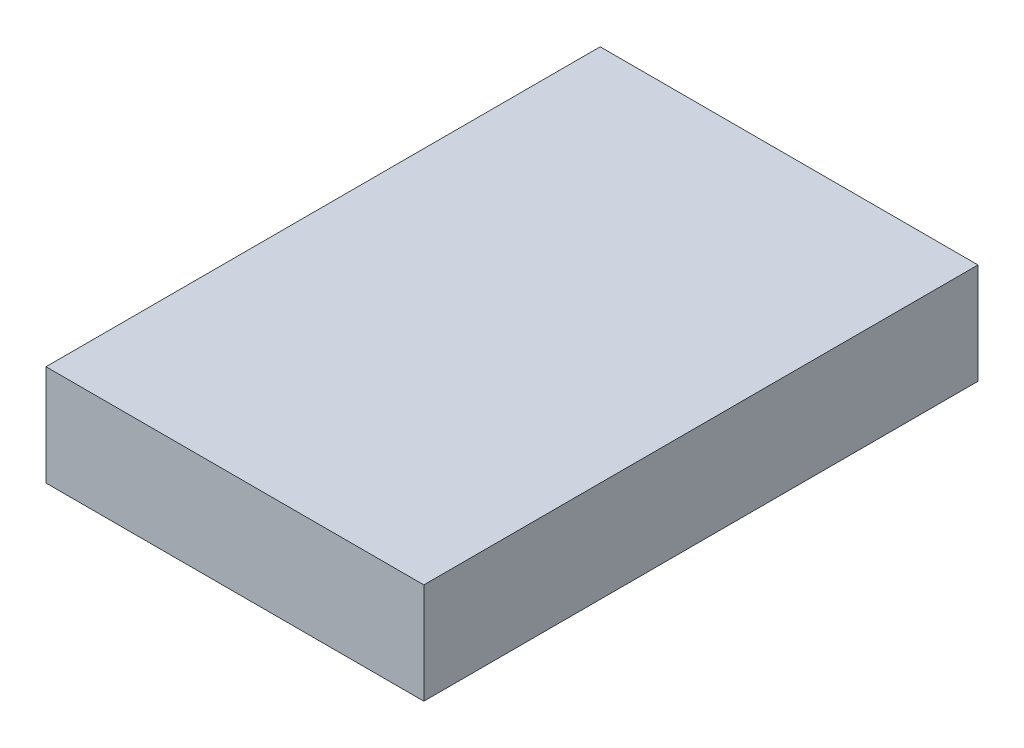
from build123d import *

# Parameters (mm, degrees)
SKETCH1_W           = 30
SKETCH1_H           = 44
BOSS_EXTRUDE1_DEPTH = 8


with BuildPart() as part:
    # Sketch1 → Boss-Extrude1 (new body)
    with BuildSketch(Plane(origin=(0, 0, 0), x_dir=(1, 0, 0), z_dir=(0, 1, 0))):
        with Locations((15, 22)):
            Rectangle(SKETCH1_W, SKETCH1_H)
    extrude(amount=BOSS_EXTRUDE1_DEPTH)


solid = part.part
